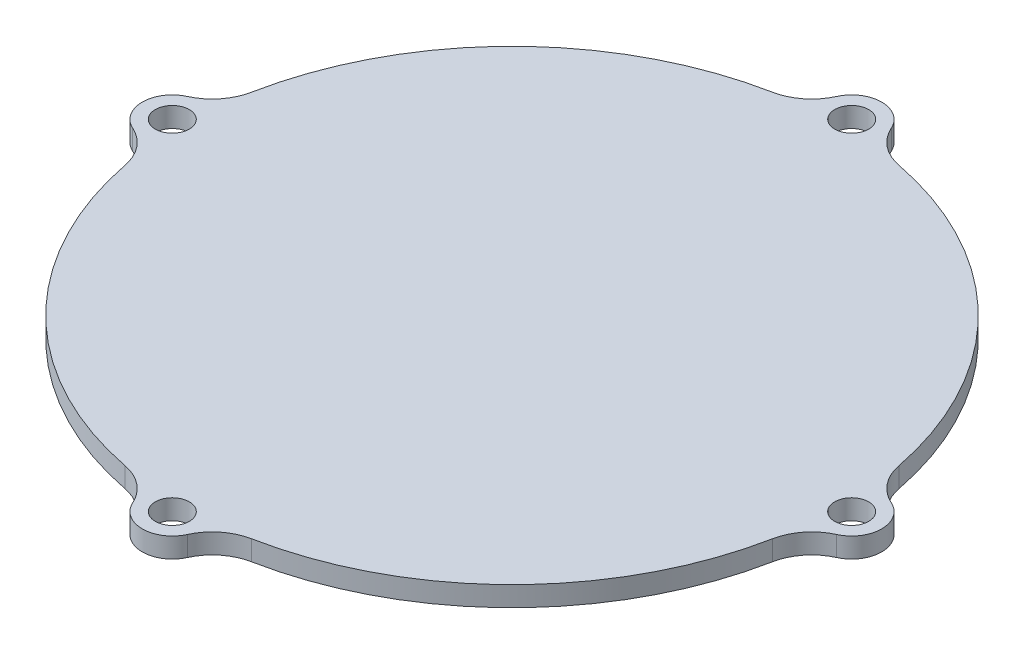
from build123d import *

# Parameters (mm, degrees)
SKETCH1_R                = 33
BOSS_EXTRUDE1_DEPTH      = 2
SKETCH2_R                = 3
BOSS_EXTRUDE2_DEPTH      = 2
FILLET1_R                = 5
CIRPATTERN1_COUNT        = 4
FILLET1_OF_CIRPATTERN1_R = 5
M3_CLEARANCE_HOLE1_D     = 3.4


with BuildPart() as part:
    # Sketch1 → Boss-Extrude1 (new body)
    with BuildSketch(Plane(origin=(0, 0, 0), x_dir=(1, 0, 0), z_dir=(0, 1, 0))):
        Circle(SKETCH1_R)
    extrude(amount=BOSS_EXTRUDE1_DEPTH)

    # Sketch2 → Boss-Extrude2 (add, through all)
    with BuildSketch(Plane(origin=(0, 2, 0), x_dir=(1, 0, 0), z_dir=(0, 1, 0))):
        with Locations((0, 34)):
            Circle(SKETCH2_R)
    boss_extrude2 = extrude(amount=-BOSS_EXTRUDE2_DEPTH)

    # Fillet1
    fillet1_edges = [part.edges().sort_by_distance(p)[0] for p in [
        (2.784037545, 1, -32.882352941),
        (-2.784037545, 1, -32.882352941),
    ]]
    fillet(fillet1_edges, radius=FILLET1_R)

    # CirPattern1: Boss-Extrude2 ×4 about axis
    cirpattern1_axis = Axis((0, 0, 0), (0, 1, 0))
    for i in range(1, CIRPATTERN1_COUNT):
        add(boss_extrude2.rotate(cirpattern1_axis, i * 360 / CIRPATTERN1_COUNT))

    # Fillet1 of CirPattern1
    fillet1_of_cirpattern1_edges = [part.edges().sort_by_distance(p)[0] for p in [
        (-32.882352941, 1, -2.784037545),
        (-32.882352941, 1, 2.784037545),
        (-2.784037545, 1, 32.882352941),
        (2.784037545, 1, 32.882352941),
        (32.882352941, 1, 2.784037545),
        (32.882352941, 1, -2.784037545),
    ]]
    fillet(fillet1_of_cirpattern1_edges, radius=FILLET1_OF_CIRPATTERN1_R)

    # M3 Clearance Hole1 (through all)
    with Locations(Plane(origin=(0, 2, 0), x_dir=(1, 0, 0), z_dir=(0, 1, 0))):
        with Locations((0, -34), (34, 0), (0, 34), (-34, 0)):
            Hole(M3_CLEARANCE_HOLE1_D / 2)


solid = part.part
